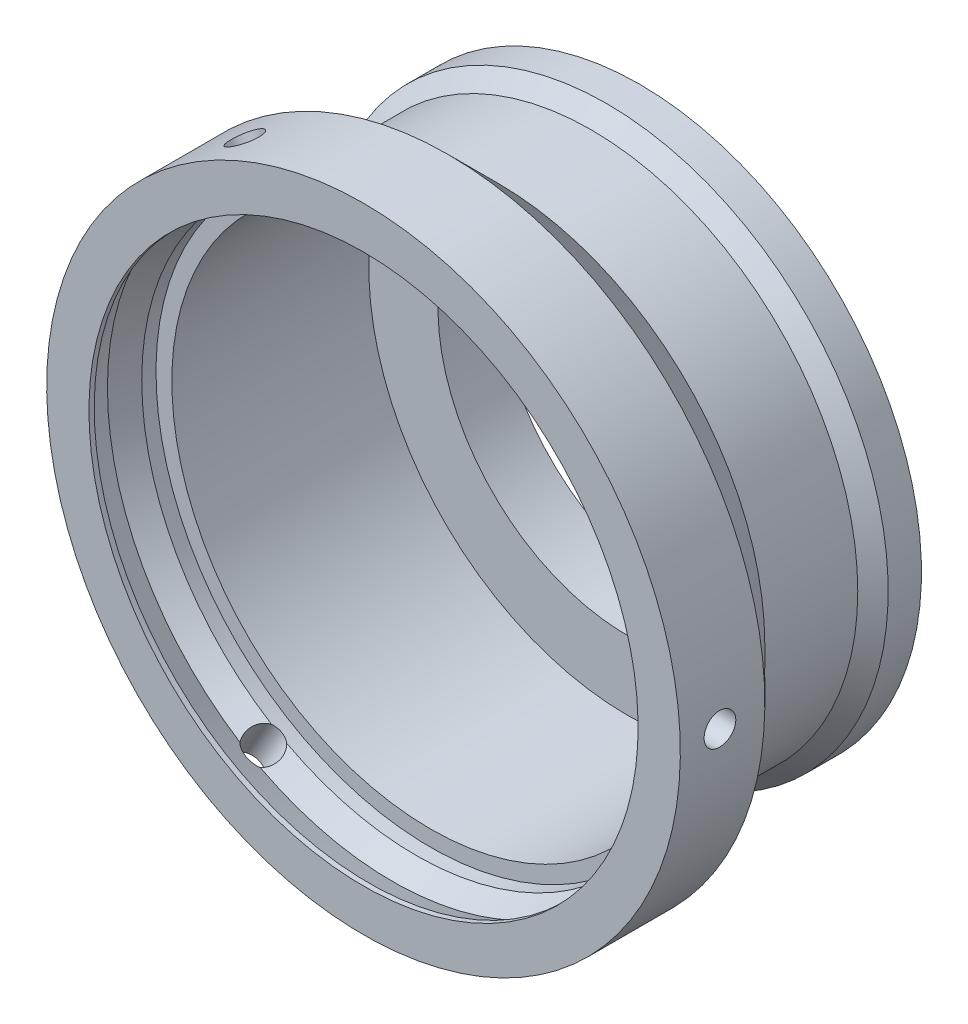
from build123d import *

# Parameters (mm, degrees)
ODEBRAT_START            = 25.986775
SKICA3_R                 = 1.5
ODEBRAT_VYSUNUT_M1_DEPTH = 4.013225
KRUHOV_POLE1_COUNT       = 3
SKICA4_R                 = 1
ODEBRAT_VYSUNUT_M2_DEPTH = 0.25


with BuildPart() as part:
    # Skica2 → Rotovat1 (revolve)
    with BuildSketch(Plane(origin=(0, 0, 0), x_dir=(0, 0, -1), z_dir=(1, 0, 0))):
        Polygon((-14.96, 17.955), (-14.96, 19.305), (-15.46, 19.805), (-16.3, 19.805), (-16.3, 19.155), (-18.3, 19.155), (-18.3, 20.5), (-19.3, 20.5), (-19.3, 26.67), (-22.45, 26.67), (-23.89, 25.23), (-32.69, 25.23), (-37.46, 30), (-45.46, 30), (-45.46, 26), (-44.96, 26), (-42.71, 27), (-40.46, 26), (-39.11, 26), (-39.11, 24.5), (-20.46, 24.5), (-20.46, 17.955), align=None)
    revolve(axis=Axis((0, 0, 0), (0, 0, 1)))

    # Skica3 → Odebrat vysunutím1 (cut)
    with BuildSketch(Plane(origin=(0, 0, 0), x_dir=(0, 0, -1), z_dir=(1, 0, 0)).offset(ODEBRAT_START)):
        with Locations((-41.71, 0)):
            Circle(SKICA3_R)
    odebrat_vysunut_m1 = extrude(amount=ODEBRAT_VYSUNUT_M1_DEPTH, mode=Mode.SUBTRACT)

    # Kruhové pole1: Odebrat vysunutím1 ×3 about axis
    kruhov_pole1_axis = Axis((0, 0, 0), (0, 0, -1))
    for i in range(1, KRUHOV_POLE1_COUNT):
        add(odebrat_vysunut_m1.rotate(kruhov_pole1_axis, i * 360 / KRUHOV_POLE1_COUNT), mode=Mode.SUBTRACT)

    # Skica4 → Odebrat vysunutím2 (cut)
    with BuildSketch(Plane(origin=(0, 0, 19.3), x_dir=(-1, 0, 0), z_dir=(0, 0, -1))):
        with Locations((0, 24.27)):
            Circle(SKICA4_R)
    extrude(amount=-ODEBRAT_VYSUNUT_M2_DEPTH, mode=Mode.SUBTRACT)


solid = part.part
